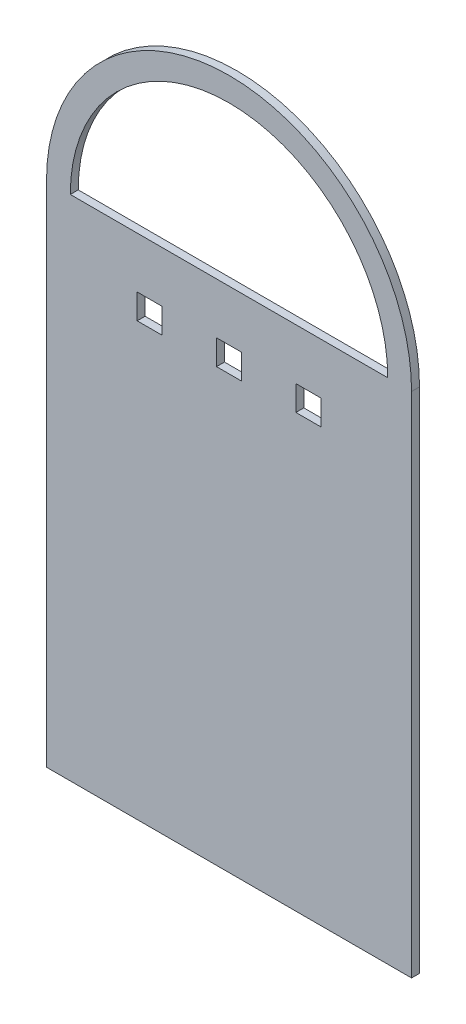
from build123d import *

# Parameters (mm, degrees)
SKETCH2_W           = 10
SKETCH2_H           = 10
BOSS_EXTRUDE5_DEPTH = 3.175


with BuildPart() as part:
    # Sketch2 → Boss-Extrude5 (new body)
    with BuildSketch(Plane.XY):
        with BuildLine():
            Line((0, 0), (146.05, 0))
            Line((146.05, 0), (146.05, 203.2))
            ThreePointArc((146.05, 203.2), (73.025, 276.225), (0, 203.2))
            Line((0, 203.2), (0, 0))
        make_face()
        with BuildLine():
            Line((9.525, 203.2), (136.525, 203.2))
            ThreePointArc((136.525, 203.2), (73.025, 266.7), (9.525, 203.2))
        make_face(mode=Mode.SUBTRACT)
        with Locations((41.275, 177.8)):
            Rectangle(SKETCH2_W, SKETCH2_H, mode=Mode.SUBTRACT)
        with Locations((73.025, 177.8)):
            Rectangle(SKETCH2_W, SKETCH2_H, mode=Mode.SUBTRACT)
        with Locations((104.775, 177.8)):
            Rectangle(SKETCH2_W, SKETCH2_H, mode=Mode.SUBTRACT)
    extrude(amount=BOSS_EXTRUDE5_DEPTH)


solid = part.part
